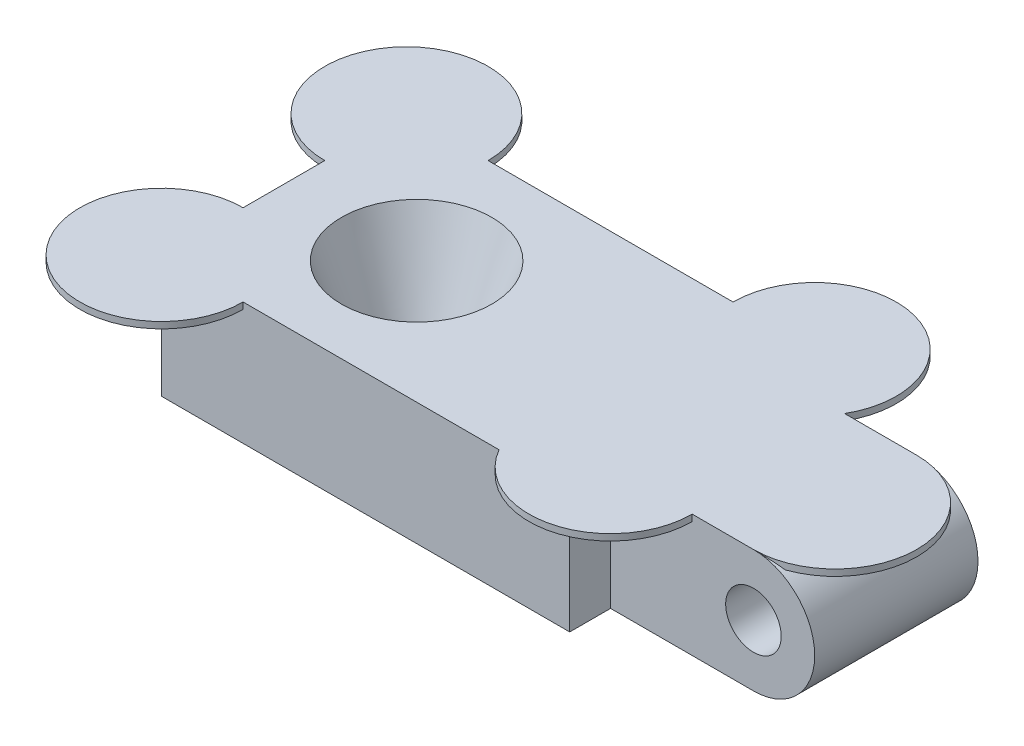
from build123d import *

# Parameters (mm, degrees)
BOSS_EXTRUDE1_DEPTH   = 10.16
F_4_CLEARANCE_HOLE1_D = 3.4544
SKETCH4_R             = 1.905
CUT_EXTRUDE1_DEPTH    = 8.62
CUT_EXTRUDE1_TAPER    = -20
SKETCH5_R             = 4.1275
CUT_EXTRUDE2_DEPTH    = 1.27
SKETCH6_W             = 25.4
SKETCH6_H             = 2.54
BOSS_EXTRUDE2_DEPTH   = 7.62
SKETCH7_R             = 5.08
PRINTTABS_DEPTH       = 0.4


with BuildPart() as part:
    # Sketch1 → Boss-Extrude1 (new body)
    with BuildSketch(Plane.XY):
        with BuildLine():
            Line((-17.145, -3.81), (17.145, -3.81))
            ThreePointArc((17.145, -3.81), (20.955, 0), (17.145, 3.81))
            Line((17.145, 3.81), (-17.145, 3.81))
            Line((-17.145, 3.81), (-17.145, -3.81))
        make_face()
    extrude(amount=BOSS_EXTRUDE1_DEPTH)

    # #4 Clearance Hole1 (through all)
    with Locations(Plane.XY.offset(10.16)):
        with Locations((17.145, 0)):
            Hole(F_4_CLEARANCE_HOLE1_D / 2)

    # Sketch4 → Cut-Extrude1 (cut, through all)
    with BuildSketch(Plane(origin=(0, -3.81, 0), x_dir=(1, 0, 0), z_dir=(0, 1, 0))):
        with Locations((-8.89, -5.08)):
            Circle(SKETCH4_R)
    extrude(amount=CUT_EXTRUDE1_DEPTH, taper=CUT_EXTRUDE1_TAPER, mode=Mode.SUBTRACT)

    # Sketch5 → Cut-Extrude2 (cut)
    with BuildSketch(Plane.XZ.offset(3.81)):
        with Locations((-8.89, 5.08)):
            Circle(SKETCH5_R)
    extrude(amount=-CUT_EXTRUDE2_DEPTH, mode=Mode.SUBTRACT)

    # Sketch6 → Boss-Extrude2 (add, through all)
    with BuildSketch(Plane.XZ.offset(3.81)):
        with Locations((-4.445, 11.43)):
            Rectangle(SKETCH6_W, SKETCH6_H)
        with Locations((-4.445, -1.27)):
            Rectangle(SKETCH6_W, SKETCH6_H)
    extrude(amount=-BOSS_EXTRUDE2_DEPTH)

    # Sketch7 → PrintTabs (add)
    with BuildSketch(Plane(origin=(0, 3.81, 0), x_dir=(1, 0, 0), z_dir=(0, 1, 0))):
        with Locations((8.255, 2.54)):
            Circle(SKETCH7_R)
        with Locations((-17.145, -12.7)):
            Circle(SKETCH7_R)
        with Locations((-17.145, 2.54)):
            Circle(SKETCH7_R)
        with Locations((8.255, -10.16)):
            Circle(SKETCH7_R)
        with Locations((17.145, -5.08)):
            Circle(SKETCH7_R)
    extrude(amount=-PRINTTABS_DEPTH)


solid = part.part
